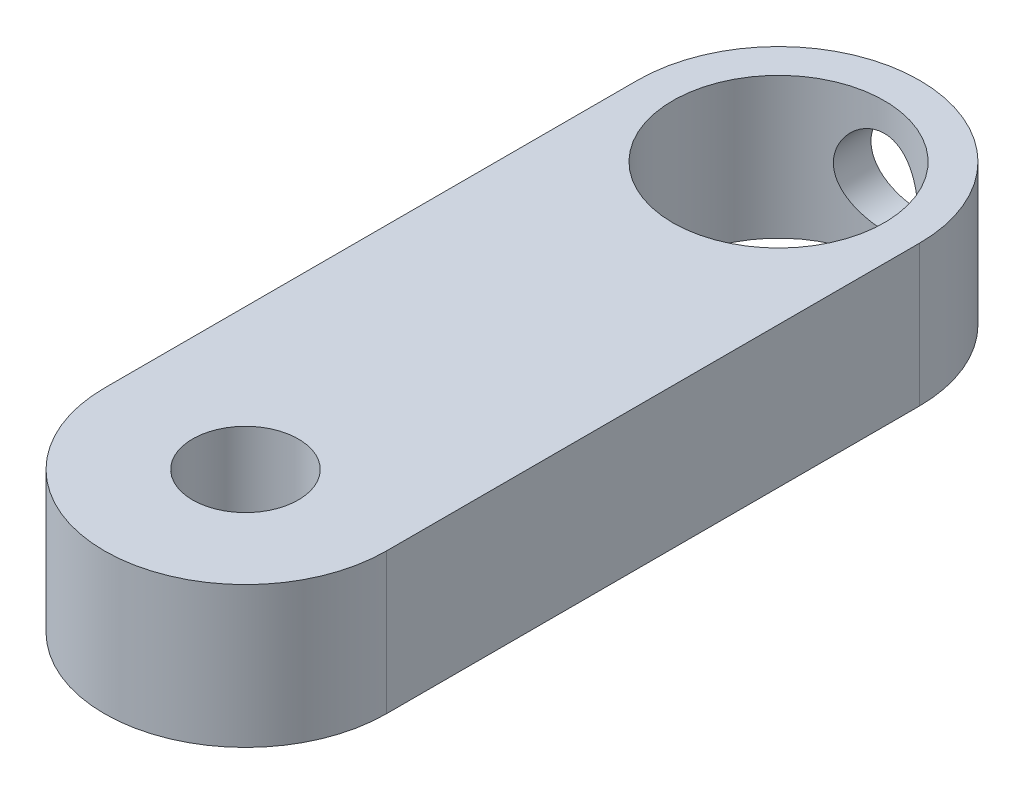
from build123d import *

# Parameters (mm, degrees)
SKETCH1_R                      = 4.7625
BOSS_EXTRUDE1_DEPTH            = 6.35
F_3_16_0_1875_DIAMETER_HOLE1_D = 4.7625
F_6_32_TAPPED_HOLE1_D          = 2.7051
F_6_32_TAPPED_HOLE1_DEPTH      = 22.352
F_6_32_TAPPED_HOLE1_TIP        = 0.81269403
F_6_CLEARANCE_HOLE1_D          = 3.7973
F_6_CLEARANCE_HOLE1_DEPTH      = 6.35
F_6_CLEARANCE_HOLE1_TIP        = 1.140824014


with BuildPart() as part:
    # Sketch1 → Boss-Extrude1 (new body)
    with BuildSketch(Plane(origin=(0, 0, 0), x_dir=(1, 0, 0), z_dir=(0, 1, 0))):
        with BuildLine():
            Line((6.35, 24), (6.35, 0))
            ThreePointArc((6.35, 0), (0, -6.35), (-6.35, 0))
            Line((-6.35, 0), (-6.35, 24))
            ThreePointArc((-6.35, 24), (0, 30.35), (6.35, 24))
        make_face()
        with Locations((0, 24)):
            Circle(SKETCH1_R, mode=Mode.SUBTRACT)
    extrude(amount=BOSS_EXTRUDE1_DEPTH)

    # 3/16 (0.1875) Diameter Hole1 (through all)
    with Locations(Plane(origin=(0, 6.35, 0), x_dir=(1, 0, 0), z_dir=(0, 1, 0))):
        with Locations((0, 0)):
            Hole(F_3_16_0_1875_DIAMETER_HOLE1_D / 2)

    # #6-32 Tapped Hole1
    with Locations(Plane(origin=(0, 0, -30.35), x_dir=(-1, 0, 0), z_dir=(0, 0, -1))):
        with Locations((0, 3.175)):
            Hole(F_6_32_TAPPED_HOLE1_D / 2, depth=F_6_32_TAPPED_HOLE1_DEPTH)
            with Locations((0, 0, -(F_6_32_TAPPED_HOLE1_DEPTH + F_6_32_TAPPED_HOLE1_TIP / 2))):  # 118° drill point
                Cone(0, F_6_32_TAPPED_HOLE1_D / 2, F_6_32_TAPPED_HOLE1_TIP, mode=Mode.SUBTRACT)

    # #6 Clearance Hole1
    with Locations(Plane(origin=(0, 0, -30.35), x_dir=(-1, 0, 0), z_dir=(0, 0, -1))):
        with Locations((0, 3.175)):
            Hole(F_6_CLEARANCE_HOLE1_D / 2, depth=F_6_CLEARANCE_HOLE1_DEPTH)
            with Locations((0, 0, -(F_6_CLEARANCE_HOLE1_DEPTH + F_6_CLEARANCE_HOLE1_TIP / 2))):  # 118° drill point
                Cone(0, F_6_CLEARANCE_HOLE1_D / 2, F_6_CLEARANCE_HOLE1_TIP, mode=Mode.SUBTRACT)


solid = part.part
